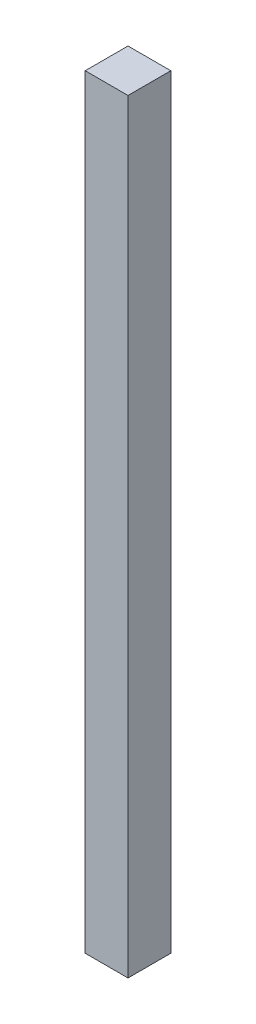
from build123d import *

# Parameters (mm, degrees)
SKETCH1_W           = 25.4
SKETCH1_H           = 25.4
BOSS_EXTRUDE1_DEPTH = 453.39


with BuildPart() as part:
    # Sketch1 → Boss-Extrude1 (new body)
    with BuildSketch(Plane(origin=(0, 0, 0), x_dir=(1, 0, 0), z_dir=(0, 1, 0))):
        with Locations((12.7, 12.7)):
            Rectangle(SKETCH1_W, SKETCH1_H)
    extrude(amount=BOSS_EXTRUDE1_DEPTH)


solid = part.part
